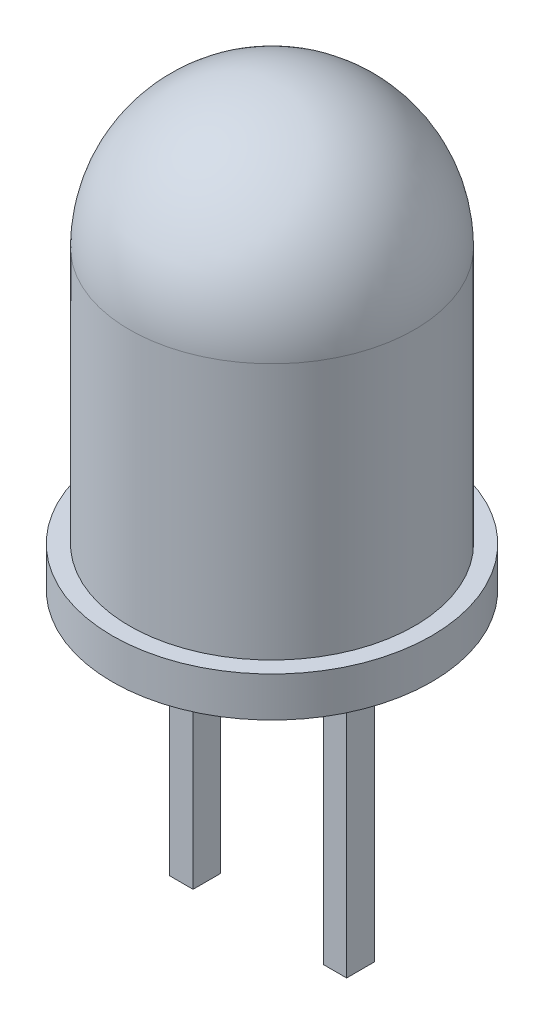
from build123d import *

# Parameters (mm, degrees)
SKETCH2_R           = 2.5
BOSS_EXTRUDE1_DEPTH = 7
SKETCH3_R           = 2.8
BOSS_EXTRUDE2_DEPTH = 0.7
FILLET1_R           = 2.5
SKETCH4_W           = 0.409361502
SKETCH4_H           = 0.4847702
BOSS_EXTRUDE3_DEPTH = 5


with BuildPart() as part:
    # Sketch2 → Boss-Extrude1 (new body)
    with BuildSketch(Plane(origin=(0, 0, 0), x_dir=(1, 0, 0), z_dir=(0, 1, 0))):
        Circle(SKETCH2_R)
    extrude(amount=BOSS_EXTRUDE1_DEPTH)

    # Sketch3 → Boss-Extrude2 (add)
    with BuildSketch(Plane.XZ):
        Circle(SKETCH3_R)
    extrude(amount=BOSS_EXTRUDE2_DEPTH)

    # Fillet1
    fillet1_edges = [part.edges().sort_by_distance(p)[0] for p in [
        (-2.5, 7, 0),
    ]]
    fillet(fillet1_edges, radius=FILLET1_R)

    # Sketch4 → Boss-Extrude3 (add)
    with BuildSketch(Plane.XZ.offset(0.7)):
        with Locations((1.346583888, 0)):
            Rectangle(SKETCH4_W, SKETCH4_H)
        with Locations((-1.346583888, 0)):
            Rectangle(SKETCH4_W, SKETCH4_H)
    extrude(amount=BOSS_EXTRUDE3_DEPTH)


solid = part.part
